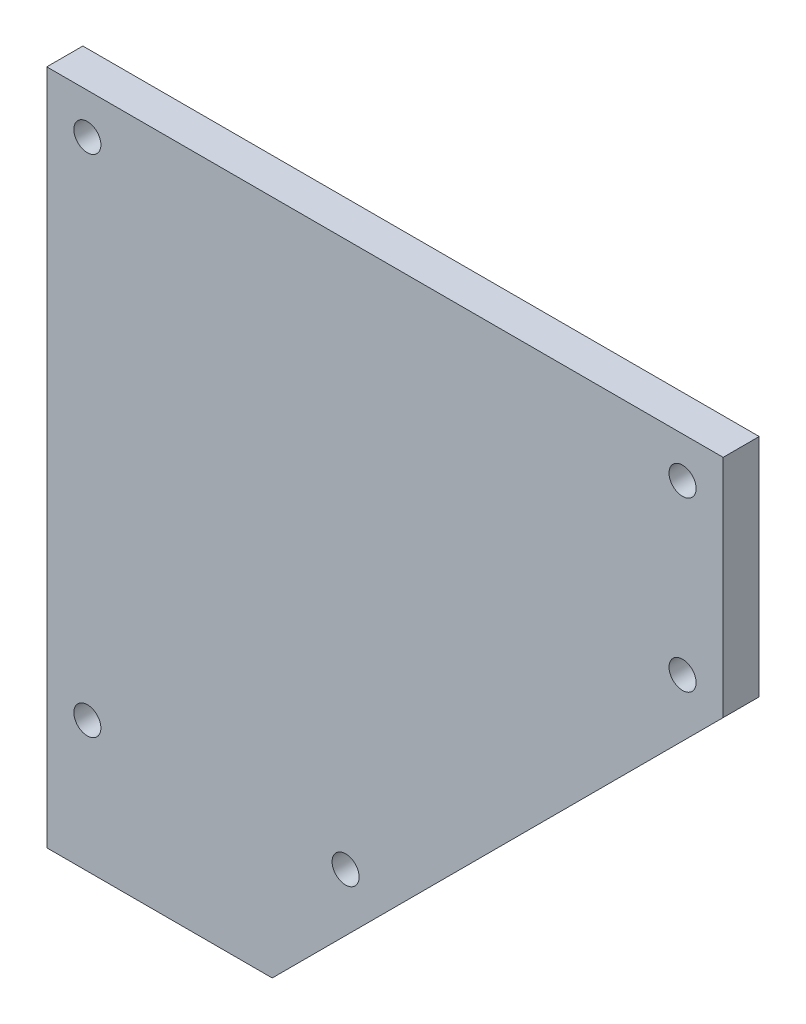
from build123d import *

# Parameters (mm, degrees)
SKETCH1_R           = 1.5
BOSS_EXTRUDE1_DEPTH = 4


with BuildPart() as part:
    # Sketch1 → Boss-Extrude1 (new body)
    with BuildSketch(Plane.XY):
        Polygon((0, 0), (0, -65), (0, -75), (25, -75), (75, -25), (75, 0), align=None)
        with Locations((4.5, -4.5)):
            Circle(SKETCH1_R, mode=Mode.SUBTRACT)
        with Locations((70.5, -4.5)):
            Circle(SKETCH1_R, mode=Mode.SUBTRACT)
        with Locations((70.5, -23.136038969)):
            Circle(SKETCH1_R, mode=Mode.SUBTRACT)
        with Locations((4.5, -60.5)):
            Circle(SKETCH1_R, mode=Mode.SUBTRACT)
        with Locations((33.136038969, -60.5)):
            Circle(SKETCH1_R, mode=Mode.SUBTRACT)
    extrude(amount=BOSS_EXTRUDE1_DEPTH)


solid = part.part
